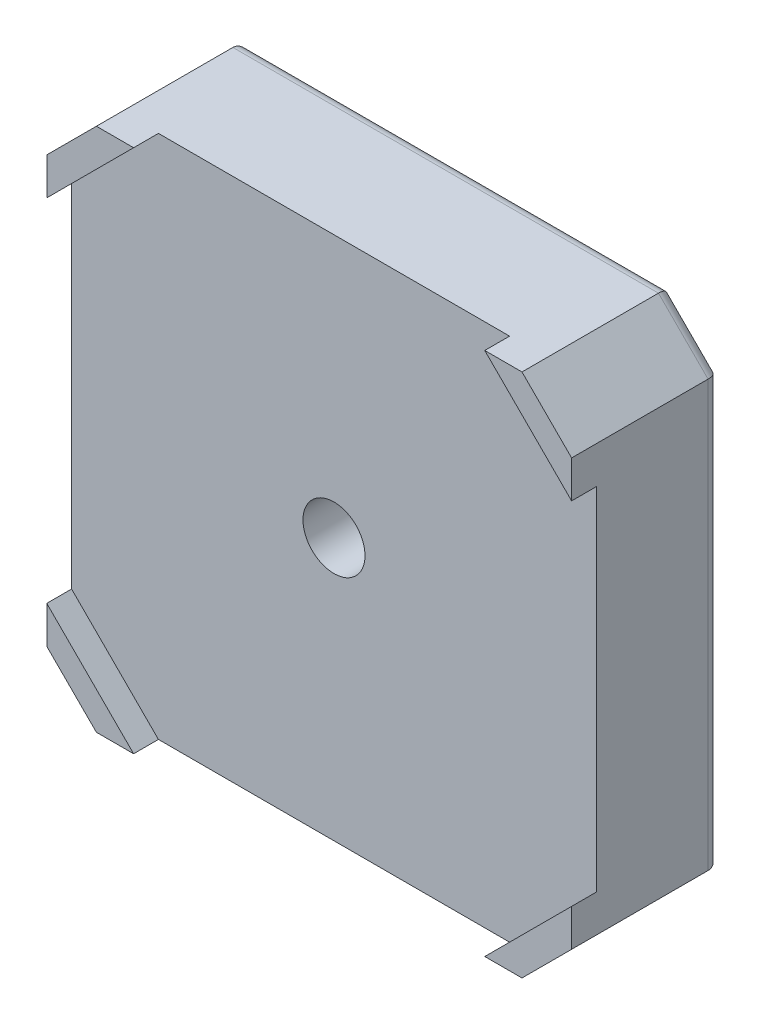
from build123d import *

# Parameters (mm, degrees)
ESTRUSIONE_ESTRUSIONE1_DEPTH = 12
TAGLIO_ESTRUSIONE1_DEPTH     = 2
SCHIZZO3_R                   = 11
ESTRUSIONE_ESTRUSIONE2_DEPTH = 2
SCHIZZO4_R                   = 5.5
TAGLIO_ESTRUSIONE2_DEPTH     = 7
SCHIZZO5_R                   = 2.5
TAGLIO_ESTRUSIONE3_DEPTH     = 8
RACCORDO1_R                  = 1
RACCORDO2_R                  = 0.5
SCHIZZO6_R                   = 1.5
TAGLIO_ESTRUSIONE4_DEPTH     = 3
RACCORDO3_R                  = 0.5


with BuildPart() as part:
    # Schizzo1 → Estrusione-Estrusione1 (new body)
    with BuildSketch(Plane.XY):
        Polygon((-21.15, 17.15), (-17.15, 21.15), (17.15, 21.15), (21.15, 17.15), (21.15, -17.15), (17.15, -21.15), (-17.15, -21.15), (-21.15, -17.15), align=None)
    extrude(amount=ESTRUSIONE_ESTRUSIONE1_DEPTH)

    # Schizzo2 → Taglio-Estrusione1 (cut)
    with BuildSketch(Plane.XY.offset(12)):
        Polygon((-21.15, 14.15), (-14.15, 21.15), (14.15, 21.15), (21.15, 14.15), (21.15, -14.15), (14.15, -21.15), (-14.15, -21.15), (-21.15, -14.15), align=None)
    extrude(amount=-TAGLIO_ESTRUSIONE1_DEPTH, mode=Mode.SUBTRACT)

    # Schizzo3 → Estrusione-Estrusione2 (add)
    with BuildSketch(Plane(origin=(0, 0, 0), x_dir=(-1, 0, 0), z_dir=(0, 0, -1))):
        Circle(SCHIZZO3_R)
    extrude(amount=ESTRUSIONE_ESTRUSIONE2_DEPTH)

    # Schizzo4 → Taglio-Estrusione2 (cut)
    with BuildSketch(Plane(origin=(0, 0, -2), x_dir=(-1, 0, 0), z_dir=(0, 0, -1))):
        Circle(SCHIZZO4_R)
    extrude(amount=-TAGLIO_ESTRUSIONE2_DEPTH, mode=Mode.SUBTRACT)

    # Schizzo5 → Taglio-Estrusione3 (cut, through all)
    with BuildSketch(Plane(origin=(0, 0, 5), x_dir=(-1, 0, 0), z_dir=(0, 0, -1))):
        Circle(SCHIZZO5_R)
    extrude(amount=-TAGLIO_ESTRUSIONE3_DEPTH, mode=Mode.SUBTRACT)

    # Raccordo1
    raccordo1_edges = [part.edges().sort_by_distance(p)[0] for p in [
        (19.15, -19.15, 0),
        (0, -21.15, 0),
        (-19.15, -19.15, 0),
        (-21.15, 0, 0),
        (-19.15, 19.15, 0),
        (0, 21.15, 0),
        (19.15, 19.15, 0),
        (21.15, 0, 0),
    ]]
    fillet(raccordo1_edges, radius=RACCORDO1_R)

    # Raccordo2
    raccordo2_edges = [part.edges().sort_by_distance(p)[0] for p in [
        (11, 0, -2),
        (5.5, 0, 5),
        (5.5, 0, -2),
    ]]
    fillet(raccordo2_edges, radius=RACCORDO2_R)

    # Schizzo6 → Taglio-Estrusione4 (cut)
    with BuildSketch(Plane(origin=(0, 0, 0), x_dir=(-1, 0, 0), z_dir=(0, 0, -1))):
        with Locations((-15.5, 15.5)):
            Circle(SCHIZZO6_R)
        with Locations((15.5, 15.5)):
            Circle(SCHIZZO6_R)
        with Locations((15.5, -15.5)):
            Circle(SCHIZZO6_R)
        with Locations((-15.5, -15.5)):
            Circle(SCHIZZO6_R)
    extrude(amount=-TAGLIO_ESTRUSIONE4_DEPTH, mode=Mode.SUBTRACT)

    # Raccordo3
    raccordo3_edges = [part.edges().sort_by_distance(p)[0] for p in [
        (17, -15.5, 0),
        (-14, -15.5, 0),
        (-14, 15.5, 0),
        (17, 15.5, 0),
    ]]
    fillet(raccordo3_edges, radius=RACCORDO3_R)


solid = part.part
